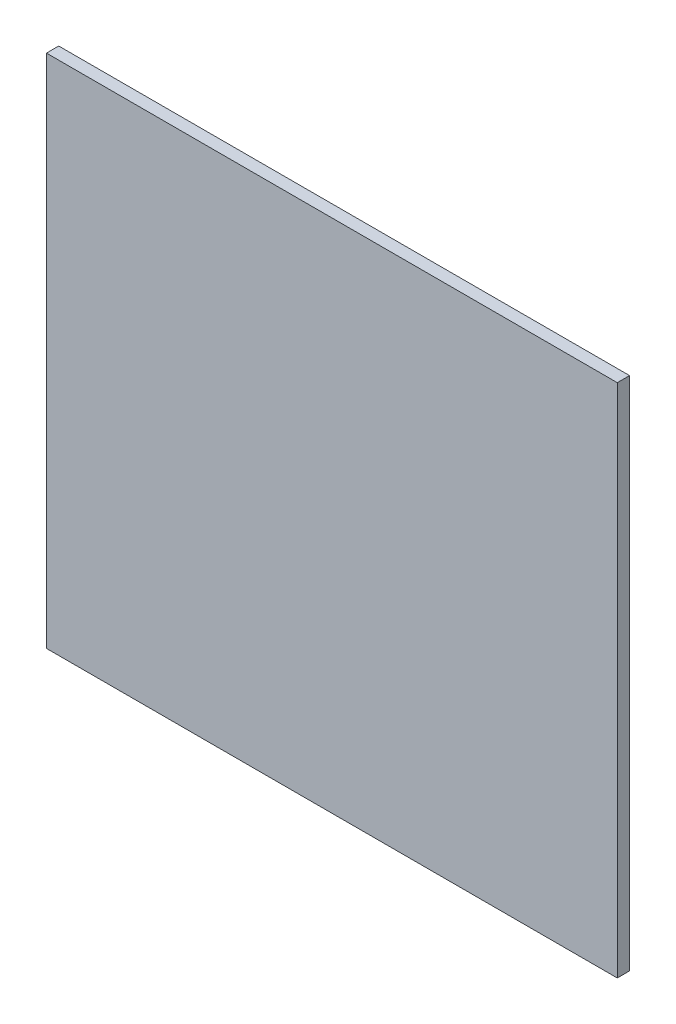
from build123d import *

# Parameters (mm, degrees)
SKETCH1_W           = 93
SKETCH1_H           = 84
BOSS_EXTRUDE1_DEPTH = 2


with BuildPart() as part:
    # Sketch1 → Boss-Extrude1 (new body)
    with BuildSketch(Plane.XY):
        with Locations((0, 5.787663458)):
            Rectangle(SKETCH1_W, SKETCH1_H)
    extrude(amount=BOSS_EXTRUDE1_DEPTH)


solid = part.part
